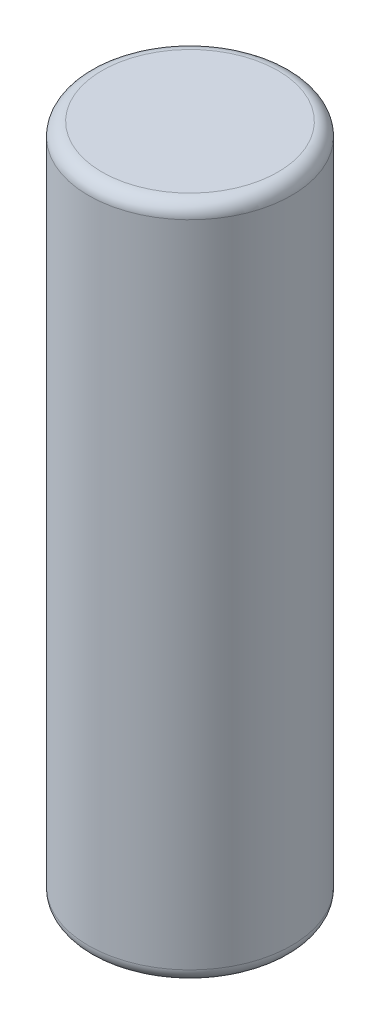
from build123d import *

# Parameters (mm, degrees)
ESQUISSE1_R        = 1.5
BOSS_EXTRU_1_DEPTH = 10
CONG_1_R           = 0.2


with BuildPart() as part:
    # Esquisse1 → Boss.-Extru.1 (new body)
    with BuildSketch(Plane(origin=(0, 0, 0), x_dir=(1, 0, 0), z_dir=(0, 1, 0))):
        Circle(ESQUISSE1_R)
    extrude(amount=BOSS_EXTRU_1_DEPTH)

    # Congé1
    cong_1_edges = [part.edges().sort_by_distance(p)[0] for p in [
        (-1.5, 0, 0),
        (-1.5, 10, 0),
    ]]
    fillet(cong_1_edges, radius=CONG_1_R)


solid = part.part
